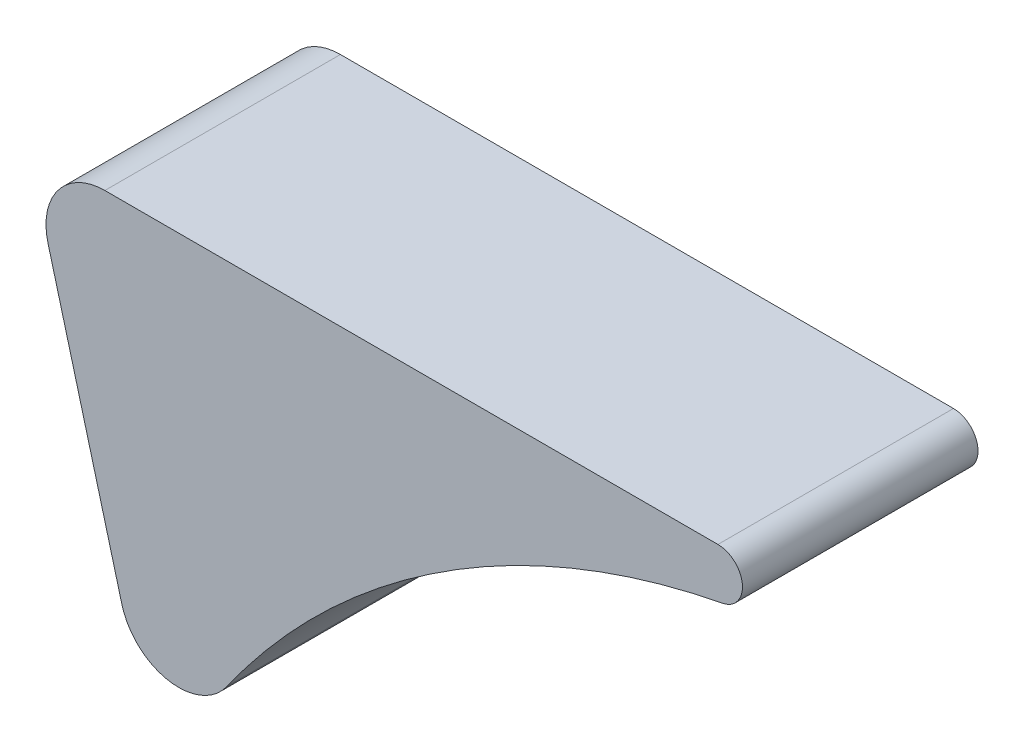
from build123d import *

# Parameters (mm, degrees)
EXTRUDE1_DEPTH = 6


with BuildPart() as part:
    # Sketch1 → Extrude1 (new body, symmetric)
    with BuildSketch(Plane.XY):
        with BuildLine():
            Line((-38.224035391, 24.175857425), (-41.98810136, 38.223542865))
            ThreePointArc((-41.98810136, 38.223542865), (-41.470383902, 40.826284287), (-39.090323881, 42))
            Line((-39.090323881, 42), (-7.854139036, 42))
            ThreePointArc((-7.854139036, 42), (-6.609799443, 40.868823297), (-7.617568583, 39.522590361))
            ThreePointArc((-7.617568583, 39.522590361), (-21.825698531, 33.818654373), (-32.875881641, 23.221518175))
            ThreePointArc((-32.875881641, 23.221518175), (-35.853261528, 21.99896609), (-38.224035391, 24.175857425))
        make_face()
    extrude(amount=EXTRUDE1_DEPTH, both=True)


solid = part.part
